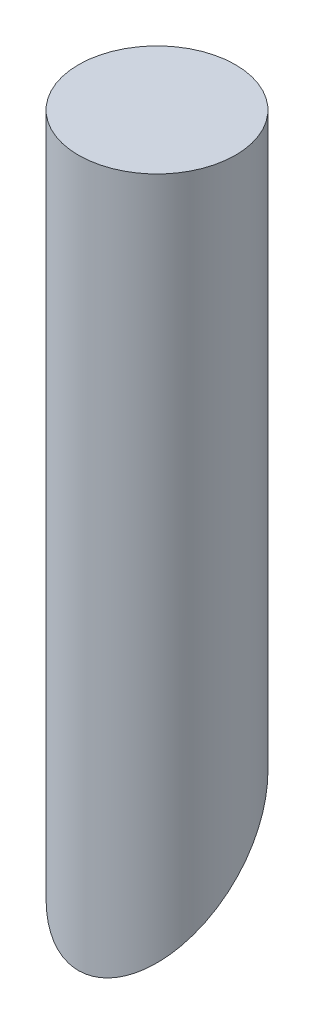
from build123d import *

# Parameters (mm, degrees)
SKETCH1_R           = 31.75
BOSS_EXTRUDE1_DEPTH = 222.25
SKETCH2_R           = 31.75
BOSS_EXTRUDE2_DEPTH = 63.5
CUT_EXTRUDE1_DEPTH  = 63.5


with BuildPart() as part:
    # Sketch1 → Boss-Extrude1 (new body)
    with BuildSketch(Plane(origin=(0, 0, 0), x_dir=(1, 0, 0), z_dir=(0, 1, 0))):
        Circle(SKETCH1_R)
    extrude(amount=BOSS_EXTRUDE1_DEPTH)

    # Sketch2 → Boss-Extrude2 (add)
    with BuildSketch(Plane.XZ):
        Circle(SKETCH2_R)
    extrude(amount=BOSS_EXTRUDE2_DEPTH)

    # Sketch3 → Cut-Extrude1 (cut)
    with BuildSketch(Plane(origin=(31.75, 0, 0), x_dir=(0, 0, -1), z_dir=(1, 0, 0))):
        Polygon((31.75, 0), (31.75, -63.5), (-31.75, -63.5), align=None)
    extrude(amount=-CUT_EXTRUDE1_DEPTH, mode=Mode.SUBTRACT)


solid = part.part
